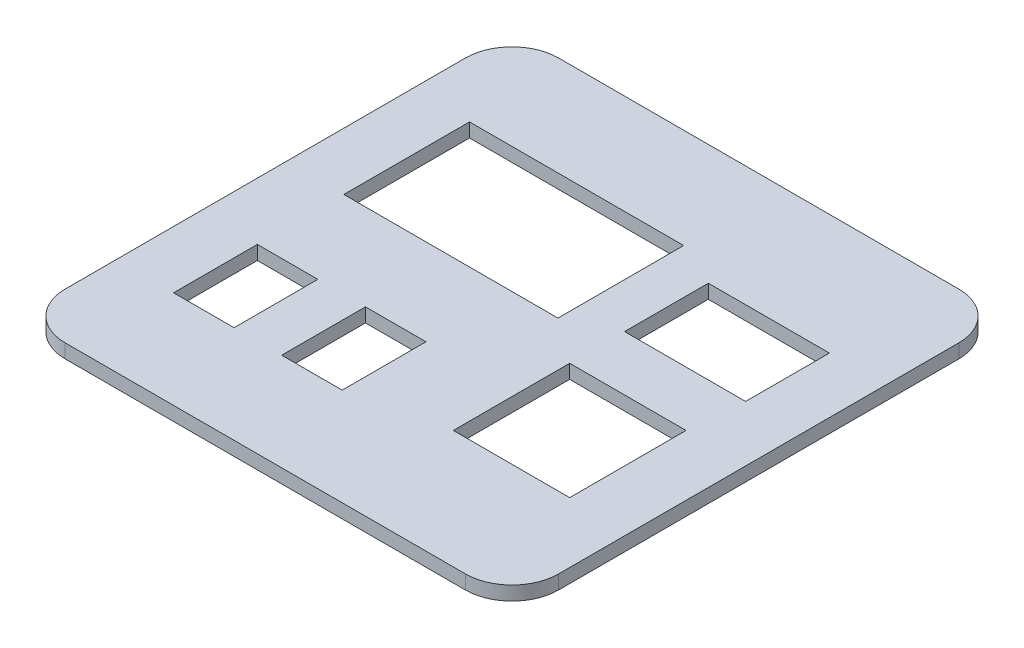
from build123d import *

# Parameters (mm, degrees)
SKETCH1_W           = 25
SKETCH1_H           = 25
SKETCH1_W_2         = 26
SKETCH1_H_2         = 18
SKETCH1_W_3         = 46
SKETCH1_H_3         = 27
SKETCH1_W_4         = 13
BOSS_EXTRUDE1_DEPTH = 3


with BuildPart() as part:
    # Sketch1 → Boss-Extrude1 (new body)
    with BuildSketch(Plane(origin=(0, 0, 0), x_dir=(1, 0, 0), z_dir=(0, 1, 0))):
        with BuildLine():
            ThreePointArc((43, 53), (50.071067812, 50.071067812), (53, 43))
            Line((53, 43), (53, -43))
            ThreePointArc((53, -43), (50.071067812, -50.071067812), (43, -53))
            Line((43, -53), (-43, -53))
            ThreePointArc((-43, -53), (-50.071067812, -50.071067812), (-53, -43))
            Line((-53, -43), (-53, 43))
            ThreePointArc((-53, 43), (-50.071067812, 50.071067812), (-43, 53))
            Line((-43, 53), (43, 53))
        make_face()
        with BuildLine():
            Line((-40, 50), (40, 50))
            ThreePointArc((40, 50), (47.071067812, 47.071067812), (50, 40))
            Line((50, 40), (50, -40))
            ThreePointArc((50, -40), (47.071067812, -47.071067812), (40, -50))
            Line((40, -50), (-40, -50))
            ThreePointArc((-40, -50), (-47.071067812, -47.071067812), (-50, -40))
            Line((-50, -40), (-50, 40))
            ThreePointArc((-50, 40), (-47.071067812, 47.071067812), (-40, 50))
        make_face(mode=Mode.SUBTRACT)
        with BuildLine():
            ThreePointArc((40, 50), (47.071067812, 47.071067812), (50, 40))
            Line((50, 40), (50, -40))
            ThreePointArc((50, -40), (47.071067812, -47.071067812), (40, -50))
            Line((40, -50), (-40, -50))
            ThreePointArc((-40, -50), (-47.071067812, -47.071067812), (-50, -40))
            Line((-50, -40), (-50, 40))
            ThreePointArc((-50, 40), (-47.071067812, 47.071067812), (-40, 50))
            Line((-40, 50), (40, 50))
        make_face()
        with Locations((27.5, -15.109148856)):
            Rectangle(SKETCH1_W, SKETCH1_H, mode=Mode.SUBTRACT)
        with Locations((28, 18.185109271)):
            Rectangle(SKETCH1_W_2, SKETCH1_H_2, mode=Mode.SUBTRACT)
        with Locations((-17.665765758, 18.038886372)):
            Rectangle(SKETCH1_W_3, SKETCH1_H_3, mode=Mode.SUBTRACT)
        with Locations((-34.165765758, -23.046005222)):
            Rectangle(SKETCH1_W_4, SKETCH1_H_2, mode=Mode.SUBTRACT)
        with Locations((-10.934651265, -23.046005222)):
            Rectangle(SKETCH1_W_4, SKETCH1_H_2, mode=Mode.SUBTRACT)
    extrude(amount=BOSS_EXTRUDE1_DEPTH)


solid = part.part
